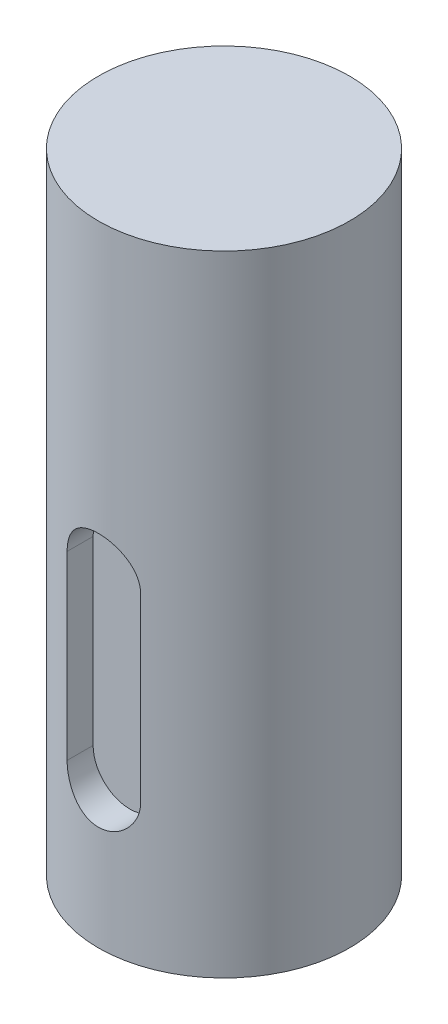
from build123d import *

# Parameters (mm, degrees)
SKETCH_1_R          = 19.95169504
EXTRUDE_1_DEPTH     = 100
CUT_EXTRUDE_1_DEPTH = 5


with BuildPart() as part:
    # 草图1 → 凸台-拉伸1 (new body)
    with BuildSketch(Plane(origin=(0, 0, 0), x_dir=(1, 0, 0), z_dir=(0, 1, 0))):
        Circle(SKETCH_1_R)
    extrude(amount=EXTRUDE_1_DEPTH)

    # 草图2 → 切除-拉伸1 (cut)
    with BuildSketch(Plane.XY.offset(19.95169504)):
        with BuildLine():
            Line((-5.839636377, 22.448895044), (-5.839636377, 51.197874129))
            ThreePointArc((-5.839636377, 51.197874129), (0, 57.037510505), (5.839636377, 51.197874129))
            Line((5.839636377, 51.197874129), (5.839636377, 22.448895044))
            ThreePointArc((5.839636377, 22.448895044), (0, 16.609258667), (-5.839636377, 22.448895044))
        make_face()
    extrude(amount=-CUT_EXTRUDE_1_DEPTH, mode=Mode.SUBTRACT)


solid = part.part
